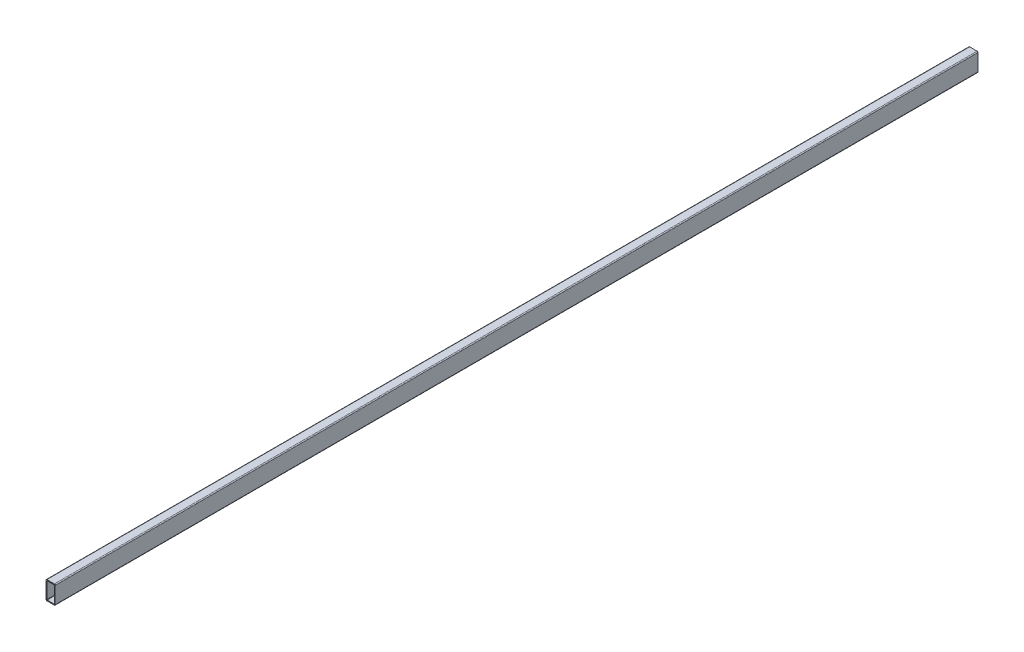
from build123d import *

# Parameters (mm, degrees)
DODANIE_WYCI_GNI_CIE1_DEPTH = 3000


with BuildPart() as part:
    # Szkic1 → Dodanie-wyciągnięcie1 (new body)
    with BuildSketch(Plane.XY):
        with BuildLine():
            Line((-8.196850851, -30), (15.803149149, -30))
            ThreePointArc((15.803149149, -30), (17.924469493, -29.121320344), (18.803149149, -27))
            Line((18.803149149, -27), (18.803149149, 27))
            ThreePointArc((18.803149149, 27), (17.924469493, 29.121320344), (15.803149149, 30))
            Line((15.803149149, 30), (-8.196850851, 30))
            ThreePointArc((-8.196850851, 30), (-10.318171195, 29.121320344), (-11.196850851, 27))
            Line((-11.196850851, 27), (-11.196850851, -27))
            ThreePointArc((-11.196850851, -27), (-10.318171195, -29.121320344), (-8.196850851, -30))
        make_face()
        with BuildLine():
            Line((-7.196850851, 27), (14.803149149, 27))
            ThreePointArc((14.803149149, 27), (15.51025593, 26.707106781), (15.803149149, 26))
            Line((15.803149149, 26), (15.803149149, -26))
            ThreePointArc((15.803149149, -26), (15.51025593, -26.707106781), (14.803149149, -27))
            Line((14.803149149, -27), (-7.196850851, -27))
            ThreePointArc((-7.196850851, -27), (-7.903957632, -26.707106781), (-8.196850851, -26))
            Line((-8.196850851, -26), (-8.196850851, 26))
            ThreePointArc((-8.196850851, 26), (-7.903957632, 26.707106781), (-7.196850851, 27))
        make_face(mode=Mode.SUBTRACT)
    extrude(amount=-DODANIE_WYCI_GNI_CIE1_DEPTH)


solid = part.part
